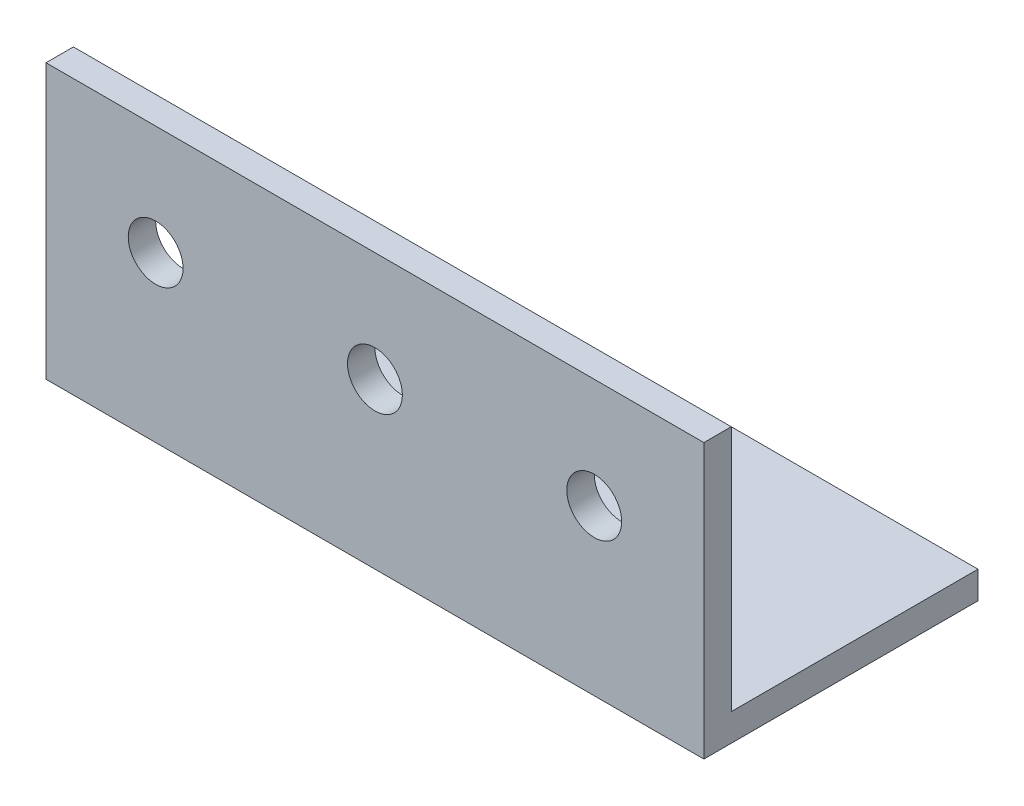
from build123d import *

# Parameters (mm, degrees)
SKETCH1_W           = 3.175
SKETCH1_H           = 28.575
BOSS_EXTRUDE1_DEPTH = 76.2
SKETCH2_R           = 3.175
CUT_EXTRUDE1_DEPTH  = 76.2


with BuildPart() as part:
    # Sketch1 → Boss-Extrude1 (new body)
    with BuildSketch(Plane(origin=(0, 0, 0), x_dir=(0, 0, -1), z_dir=(1, 0, 0))):
        with Locations((-1.5875, 14.2875)):
            Rectangle(SKETCH1_W, SKETCH1_H)
        Polygon((28.575, 0), (0, 0), (-3.175, 0), (-3.175, -3.175), (28.575, -3.175), align=None)
    extrude(amount=BOSS_EXTRUDE1_DEPTH)

    # Sketch2 → Cut-Extrude1 (cut)
    with BuildSketch(Plane(origin=(0, 0, 0), x_dir=(-1, 0, 0), z_dir=(0, 0, -1))):
        with Locations((-38.1, 15.875)):
            Circle(SKETCH2_R)
        with Locations((-63.5, 15.875)):
            Circle(SKETCH2_R)
        with Locations((-12.7, 15.875)):
            Circle(SKETCH2_R)
    extrude(amount=-CUT_EXTRUDE1_DEPTH, mode=Mode.SUBTRACT)


solid = part.part
